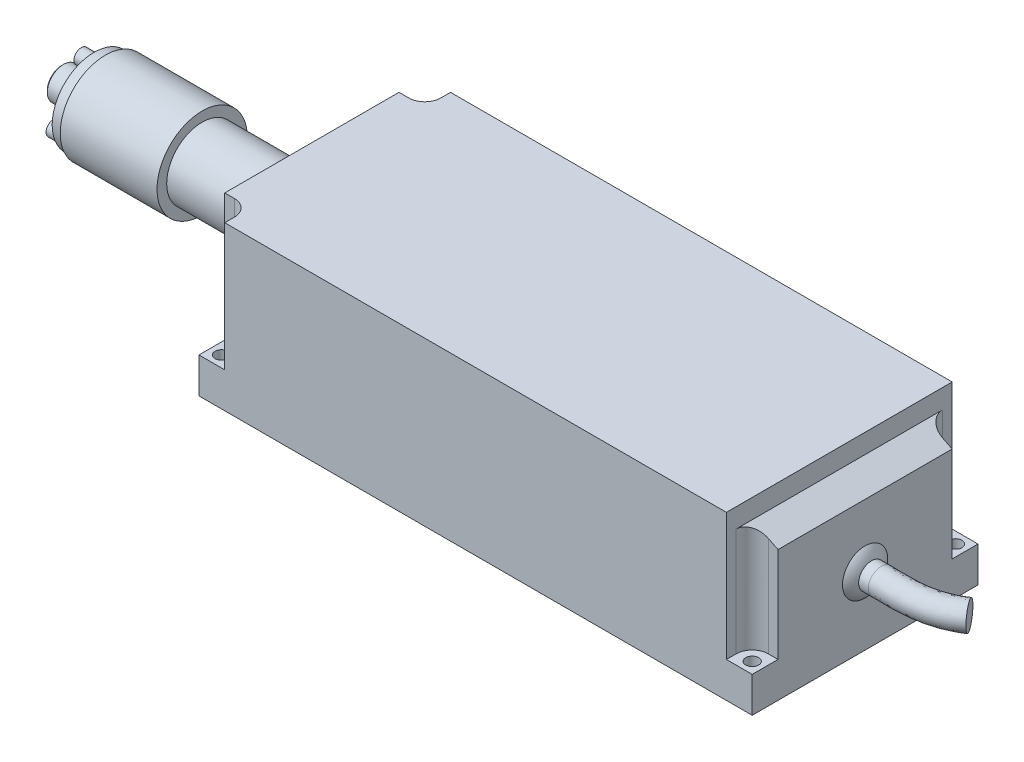
from build123d import *

# Parameters (mm, degrees)
SKETCH1_W           = 171.5
SKETCH1_H           = 70
BOSS_EXTRUDE1_DEPTH = 11
BOSS_EXTRUDE2_DEPTH = 39.5
FILLET1_R           = 5
SKETCH3_W           = 8
SKETCH3_H           = 70
CUT_EXTRUDE1_DEPTH  = 6
CUT_EXTRUDE2_REACH  = 193.996
BOSS_EXTRUDE3_DEPTH = 3
SKETCH6_R           = 11
BOSS_EXTRUDE4_DEPTH = 31
SKETCH7_R           = 14
BOSS_EXTRUDE5_DEPTH = 30
SKETCH8_R           = 13
BOSS_EXTRUDE6_DEPTH = 3.5
SKETCH9_R           = 2.25
BOSS_EXTRUDE7_DEPTH = 4
CUT_EXTRUDE3_DEPTH  = 3
SKETCH11_R          = 4.5
BOSS_EXTRUDE8_DEPTH = 4
SKETCH12_R          = 5
BOSS_EXTRUDE9_DEPTH = 6
CHAMFER1_SIZE       = 0.5
SKETCH13_R          = 2
CUT_EXTRUDE4_DEPTH  = 11
SKETCH15_R          = 4


with BuildPart() as part:
    # Sketch1 → Boss-Extrude1 (new body)
    with BuildSketch(Plane(origin=(0, 0, 0), x_dir=(1, 0, 0), z_dir=(0, 1, 0))):
        with Locations((85.75, 0)):
            Rectangle(SKETCH1_W, SKETCH1_H)
    extrude(amount=BOSS_EXTRUDE1_DEPTH)

    # Sketch2 → Boss-Extrude2 (add)
    with BuildSketch(Plane(origin=(0, 11, 0), x_dir=(1, 0, 0), z_dir=(0, 1, 0))):
        Polygon((0, 27), (0, -27), (8, -27), (8, -35), (163.5, -35), (163.5, -27), (171.5, -27), (171.5, 27), (163.5, 27), (163.5, 35), (8, 35), (8, 27), align=None)
    extrude(amount=BOSS_EXTRUDE2_DEPTH)

    # Fillet1
    fillet1_edges = [part.edges().sort_by_distance(p)[0] for p in [
        (8, 30.75, -27),
        (8, 30.75, 27),
        (163.5, 30.75, 27),
        (163.5, 30.75, -27),
    ]]
    fillet(fillet1_edges, radius=FILLET1_R)

    # Sketch3 → Cut-Extrude1 (cut)
    with BuildSketch(Plane(origin=(0, 50.5, 0), x_dir=(1, 0, 0), z_dir=(0, 1, 0))):
        with Locations((167.5, 0)):
            Rectangle(SKETCH3_W, SKETCH3_H)
    extrude(amount=-CUT_EXTRUDE1_DEPTH, mode=Mode.SUBTRACT)

    # Sketch4 → Cut-Extrude2 (cut, up to next)
    with BuildSketch(Plane.XY.offset(35), mode=Mode.PRIVATE) as cut_extrude2_sk1:
        Polygon((163.5, 44.5), (171.5, 40.5), (171.5, 44.5), align=None)
    cut_extrude2_tool1 = extrude(cut_extrude2_sk1.sketch, amount=-CUT_EXTRUDE2_REACH, mode=Mode.PRIVATE) & part.part
    add(cut_extrude2_tool1.solids().sort_by_distance((168.833333, 43.166667, 35))[0], mode=Mode.SUBTRACT)

    # Sketch13 → Cut-Extrude4 (cut)
    with BuildSketch(Plane(origin=(0, 11, 0), x_dir=(1, 0, 0), z_dir=(0, 1, 0))):
        with Locations(Location((3.5, 31.5, 0), (0, 0, 270))):
            Circle(SKETCH13_R)
        with Locations(Location((3.5, -31.5, 0), (0, 0, 270))):
            Circle(SKETCH13_R)
        with Locations(Location((168, -31.5, 0), (0, 0, 270))):
            Circle(SKETCH13_R)
        with Locations(Location((168, 31.5, 0), (0, 0, 270))):
            Circle(SKETCH13_R)
    extrude(amount=-CUT_EXTRUDE4_DEPTH, mode=Mode.SUBTRACT)


with BuildPart() as body_2:
    # Sketch5 → Boss-Extrude3 (new body)
    with BuildSketch(Plane.ZY):
        with BuildLine():
            Line((-12.951833847, 40.5), (12.951833847, 40.5))
            ThreePointArc((12.951833847, 40.5), (18, 28), (12.951833847, 15.5))
            Line((12.951833847, 15.5), (-12.951833847, 15.5))
            ThreePointArc((-12.951833847, 15.5), (-18, 28), (-12.951833847, 40.5))
        make_face()
    extrude(amount=BOSS_EXTRUDE3_DEPTH)

    # Sketch6 → Boss-Extrude4 (add)
    with BuildSketch(Plane.ZY.offset(3)):
        with Locations((0, 28)):
            Circle(SKETCH6_R)
    extrude(amount=BOSS_EXTRUDE4_DEPTH)


with BuildPart() as body_3:
    # Sketch7 → Boss-Extrude5 (new body)
    with BuildSketch(Plane.ZY.offset(34)):
        with Locations((0, 28)):
            Circle(SKETCH7_R)
    extrude(amount=BOSS_EXTRUDE5_DEPTH)


with BuildPart() as body_4:
    # Sketch8 → Boss-Extrude6 (new body)
    with BuildSketch(Plane.ZY.offset(64)):
        with Locations((0, 28)):
            Circle(SKETCH8_R)
    extrude(amount=BOSS_EXTRUDE6_DEPTH)

    # Sketch9 → Boss-Extrude7 (add)
    with BuildSketch(Plane.ZY.offset(67.5)):
        with Locations((0, 38)):
            Circle(SKETCH9_R)
        with Locations((8.660254038, 23)):
            Circle(SKETCH9_R)
        with Locations((-8.660254038, 23)):
            Circle(SKETCH9_R)
    extrude(amount=BOSS_EXTRUDE7_DEPTH)

    # Sketch10 → Cut-Extrude3 (cut)
    with BuildSketch(Plane.ZY.offset(71.5)):
        Polygon((1.5, 37.133974596), (1.5, 38.866025404), (0, 39.732050808), (-1.5, 38.866025404), (-1.5, 37.133974596), (0, 36.267949192), align=None)
        Polygon((10.160254038, 23.866025404), (8.660254038, 24.732050808), (7.160254038, 23.866025404), (7.160254038, 22.133974596), (8.660254038, 21.267949192), (10.160254038, 22.133974596), align=None)
        Polygon((-7.160254038, 23.866025404), (-8.660254038, 24.732050808), (-10.160254038, 23.866025404), (-10.160254038, 22.133974596), (-8.660254038, 21.267949192), (-7.160254038, 22.133974596), align=None)
    extrude(amount=-CUT_EXTRUDE3_DEPTH, mode=Mode.SUBTRACT)



with BuildPart() as body_5:
    # Sketch11 → Boss-Extrude8 (new body)
    with BuildSketch(Plane.ZY.offset(67.5)):
        with Locations((0, 28)):
            Circle(SKETCH11_R)
    extrude(amount=BOSS_EXTRUDE8_DEPTH)


with BuildPart() as body_4_1:
    add(body_4.part)

    add(body_5.part)  # Boss-Extrude9 merges body 5
    # Sketch12 → Boss-Extrude9 (add)
    with BuildSketch(Plane.ZY.offset(71.5)):
        with Locations((0, 28)):
            Circle(SKETCH12_R)
    extrude(amount=BOSS_EXTRUDE9_DEPTH)

    # Chamfer1
    chamfer1_edges = [body_4_1.edges().sort_by_distance(p)[0] for p in [
        (-77.5, 28, -5),
    ]]
    chamfer(chamfer1_edges, length=CHAMFER1_SIZE)


with BuildPart() as body_5_2:
    # Sweep1: sweep along a curve in space
    with BuildLine() as sweep1_path:
        Line((171.5, 21, 0), (176.5, 21, 0))
        add(Edge.make_bspline(
            [(176.5, 21, 0), (179.364212524, 21, 0), (187.383678788, 21, 0.380028995), (195.27639291, 21, -1.698433096), (199.375985718, 21, -4.460350641)],
            knots=[0, 0, 0, 0, 0.374775681, 1, 1, 1, 1], degree=3))
    # Sketch15 → Sweep1 (sweep)
    with BuildSketch(Plane(origin=(171.5, 0, 0), x_dir=(0, 0, -1), z_dir=(1, 0, 0))):
        with Locations((0, 21)):
            Circle(SKETCH15_R)
    sweep(path=sweep1_path.line)

    # Sketch16 → Revolve1 (revolve)
    with BuildSketch(Plane.XY, mode=Mode.PRIVATE) as revolve1_sk:
        with BuildLine():
            Line((171.5, 25), (171.5, 28))
            ThreePointArc((171.5, 28), (172.682959631, 26.621973088), (173.5, 25))
            Line((173.5, 25), (171.5, 25))
        make_face()
    revolve(revolve1_sk.sketch.rotate(Axis((171.5, 21, 0), (1, 0, 0)), 270), axis=Axis((171.5, 21, 0), (1, 0, 0)))


solid = Compound([part.part, body_2.part, body_3.part, body_4_1.part, body_5_2.part])
